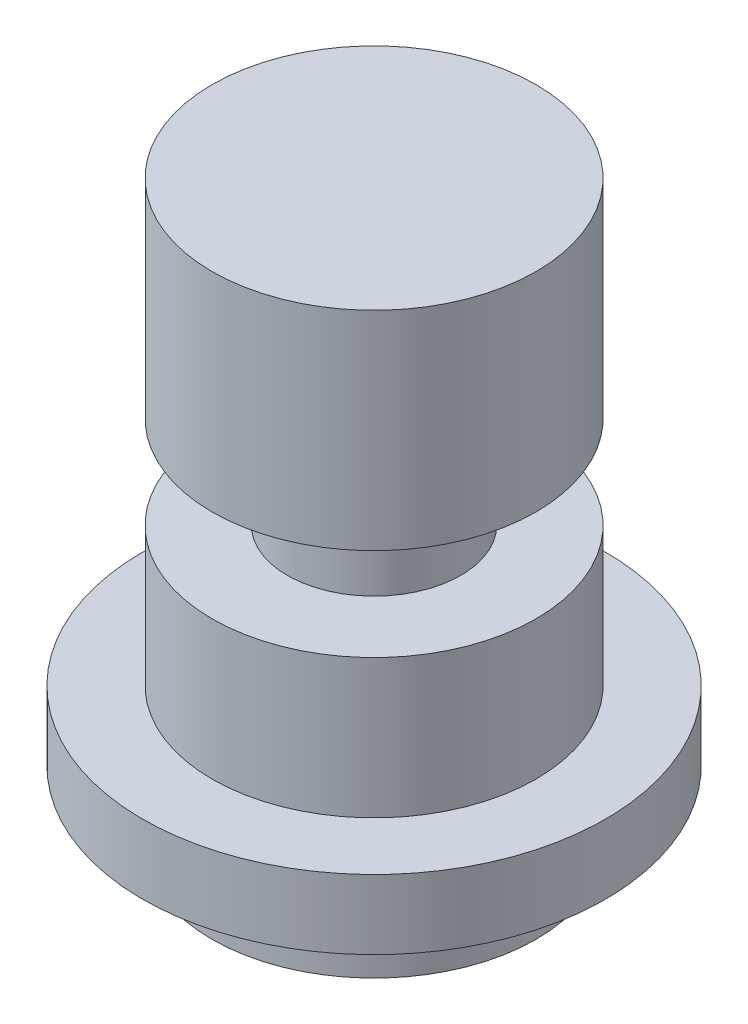
from build123d import *


with BuildPart() as part:
    # Sketch1 → Revolve1 (revolve)
    with BuildSketch(Plane.XY):
        Polygon((0, 0), (-7, 0), (-7, 3), (-10, 3), (-10, 6), (-7, 6), (-7, 12), (-3.75, 12), (-3.75, 16), (-7, 16), (-7, 25), (0, 25), align=None)
    revolve(axis=Axis((0, 25, 0), (0, -1, 0)))


solid = part.part
